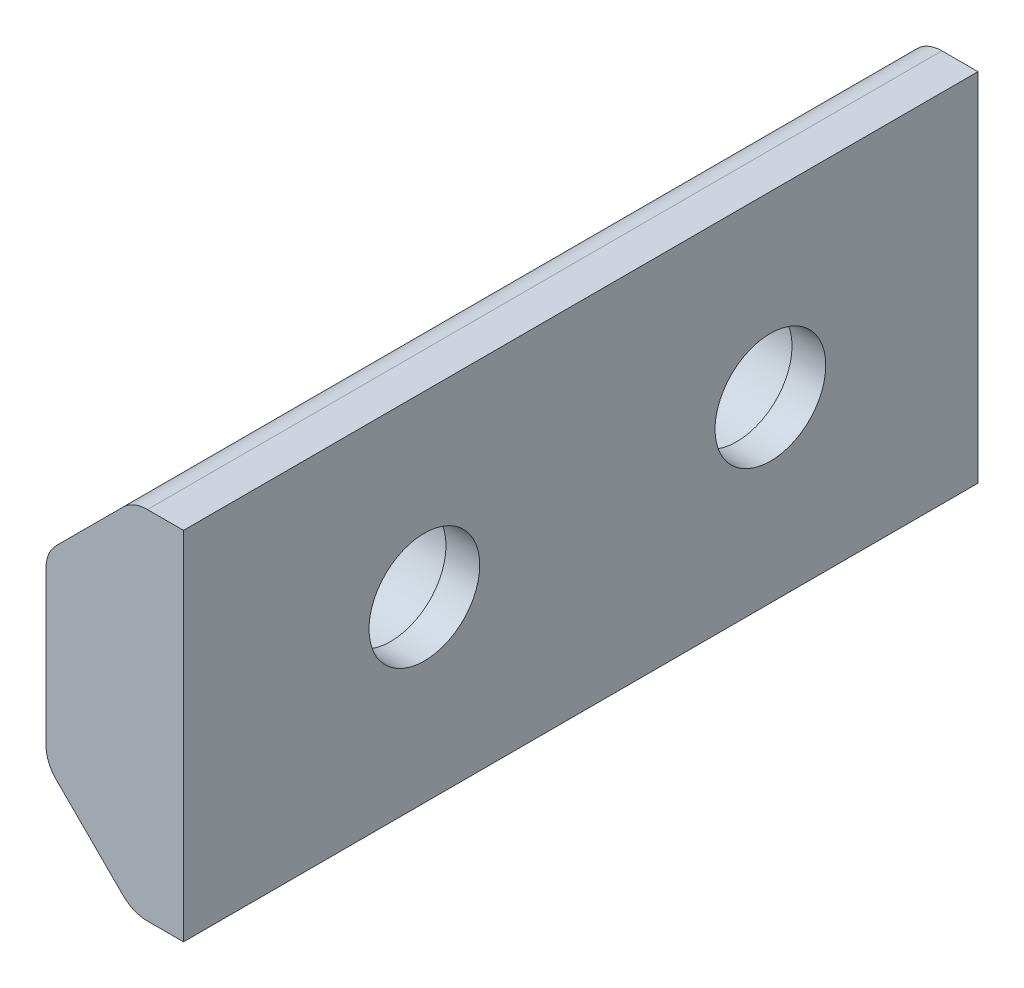
from build123d import *

# Parameters (mm, degrees)
BOSS_EXTRUDE1_DEPTH = 36
SKETCH2_R           = 1.6
CUT_EXTRUDE1_DEPTH  = 10
SKETCH3_R           = 1.95
CUT_EXTRUDE2_DEPTH  = 3
FILLET1_R           = 1
SKETCH4_W           = 8
SKETCH4_H           = 10.3
CUT_EXTRUDE3_DEPTH  = 10
SKETCH5_W           = 5.039372534
SKETCH5_H           = 10.3
CUT_EXTRUDE4_DEPTH  = 10


with BuildPart() as part:
    # Sketch1 → Boss-Extrude1 (new body)
    with BuildSketch(Plane.XY):
        Polygon((1.933806537, 5.15), (1.933806537, -5.15), (0.476512405, -5.15), (-2.040358106, -2.633129489), (-2.040358106, 2.633129489), (0.476512405, 5.15), align=None)
    extrude(amount=BOSS_EXTRUDE1_DEPTH)

    # Sketch2 → Cut-Extrude1 (cut)
    with BuildSketch(Plane(origin=(1.933806537, 0, 0), x_dir=(0, 0, -1), z_dir=(1, 0, 0))):
        with Locations((-16, 0)):
            Circle(SKETCH2_R)
        with Locations((-31, 0)):
            Circle(SKETCH2_R)
        with Locations((-6, 0)):
            Circle(SKETCH2_R)
    extrude(amount=-CUT_EXTRUDE1_DEPTH, mode=Mode.SUBTRACT)

    # Sketch3 → Cut-Extrude2 (cut)
    with BuildSketch(Plane.ZY.offset(2.040358106)):
        with Locations((16, 0)):
            Circle(SKETCH3_R)
        with Locations((31, 0)):
            Circle(SKETCH3_R)
        with Locations((6, 0)):
            Circle(SKETCH3_R)
    extrude(amount=-CUT_EXTRUDE2_DEPTH, mode=Mode.SUBTRACT)

    # Fillet1
    fillet1_edges = [part.edges().sort_by_distance(p)[0] for p in [
        (0.476512405, 5.15, 18),
        (0.476512405, -5.15, 18),
        (-2.040358106, 2.633129489, 18),
        (-2.040358106, -2.633129489, 18),
    ]]
    fillet(fillet1_edges, radius=FILLET1_R)

    # Sketch4 → Cut-Extrude3 (cut)
    with BuildSketch(Plane(origin=(1.933806537, 0, 0), x_dir=(0, 0, -1), z_dir=(1, 0, 0))):
        with Locations((-32, 0)):
            Rectangle(SKETCH4_W, SKETCH4_H)
    extrude(amount=-CUT_EXTRUDE3_DEPTH, mode=Mode.SUBTRACT)

    # Sketch5 → Cut-Extrude4 (cut)
    with BuildSketch(Plane(origin=(1.933806537, 0, 0), x_dir=(0, 0, -1), z_dir=(1, 0, 0))):
        with Locations((-25.480313733, 0)):
            Rectangle(SKETCH5_W, SKETCH5_H)
    extrude(amount=-CUT_EXTRUDE4_DEPTH, mode=Mode.SUBTRACT)


solid = part.part
